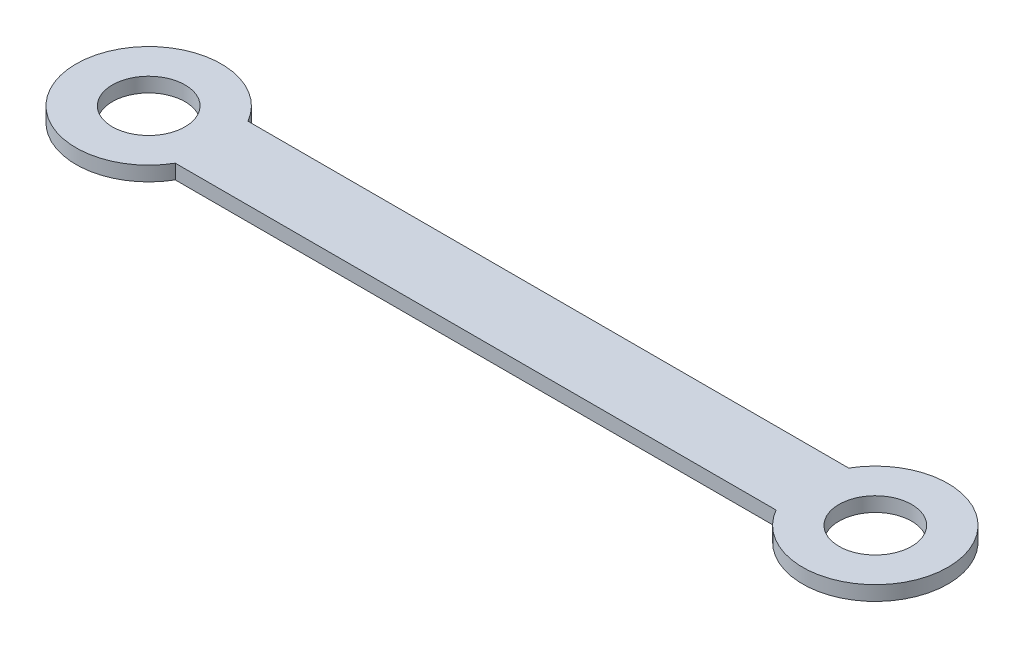
from build123d import *

# Parameters (mm, degrees)
SKETCH_5_R      = 5
EXTRUDE_1_DEPTH = 2


with BuildPart() as part:
    # 草圖5 → 填料-伸長1 (new body)
    with BuildSketch(Plane(origin=(0, 0, 0), x_dir=(1, 0, 0), z_dir=(0, 1, 0))):
        with BuildLine():
            Line((8.660254038, -5), (91.339745962, -5))
            ThreePointArc((91.339745962, -5), (110, 0), (91.339745962, 5))
            Line((91.339745962, 5), (8.660254038, 5))
            ThreePointArc((8.660254038, 5), (-10, 0), (8.660254038, -5))
        make_face()
        Circle(SKETCH_5_R, mode=Mode.SUBTRACT)
        with Locations((100, 0)):
            Circle(SKETCH_5_R, mode=Mode.SUBTRACT)
    extrude(amount=EXTRUDE_1_DEPTH)


solid = part.part
